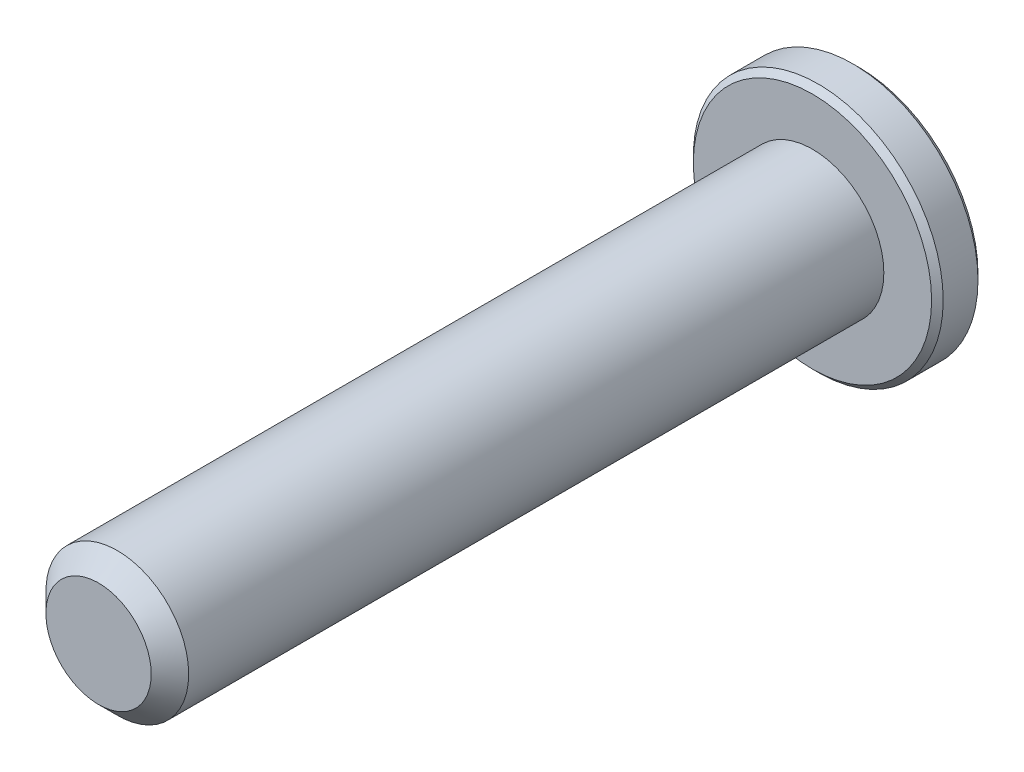
from build123d import *

# Parameters (mm, degrees)
EXTRUDE1_START     = -9.35
SKETCH1_R          = 2
EXTRUDE1_DEPTH     = 20
EXTRUDE2_START     = -10.65
SKETCH6_R          = 3.5
EXTRUDE2_DEPTH     = 1.3
CUT_EXTRUDE1_DEPTH = 0.975
SKETCH8_R          = 1.443375673
CUT_EXTRUDE2_DEPTH = 0.975
CUT_EXTRUDE2_TAPER = 45
CHAMFER1_SIZE      = 0.1625
CHAMFER2_SIZE      = 0.525


with BuildPart() as part:
    # Sketch1 → Extrude1 (new body)
    with BuildSketch(Plane.XY.offset(EXTRUDE1_START)):
        Circle(SKETCH1_R)
    extrude(amount=EXTRUDE1_DEPTH)

    # Sketch6 → Extrude2 (add)
    with BuildSketch(Plane.XY.offset(EXTRUDE2_START)):
        Circle(SKETCH6_R)
    extrude(amount=EXTRUDE2_DEPTH)

    # Sketch7 → Cut-Extrude1 (cut)
    with BuildSketch(Plane.XY.offset(-10.65)):
        Polygon((0, 1.443375673), (-1.25, 0.721687836), (-1.25, -0.721687836), (0, -1.443375673), (1.25, -0.721687836), (1.25, 0.721687836), align=None)
    extrude(amount=CUT_EXTRUDE1_DEPTH, mode=Mode.SUBTRACT)

    # Sketch8 → Cut-Extrude2 (cut)
    with BuildSketch(Plane.XY.offset(-10.65)):
        Circle(SKETCH8_R)
    extrude(amount=CUT_EXTRUDE2_DEPTH, taper=CUT_EXTRUDE2_TAPER, mode=Mode.SUBTRACT)

    # Chamfer1
    chamfer1_edges = [part.edges().sort_by_distance(p)[0] for p in [
        (-3.5, 0, -9.35),
        (-3.5, 0, -10.65),
    ]]
    chamfer(chamfer1_edges, length=CHAMFER1_SIZE)

    # Chamfer2
    chamfer2_edges = [part.edges().sort_by_distance(p)[0] for p in [
        (-2, 0, 10.65),
    ]]
    chamfer(chamfer2_edges, length=CHAMFER2_SIZE)


solid = part.part
